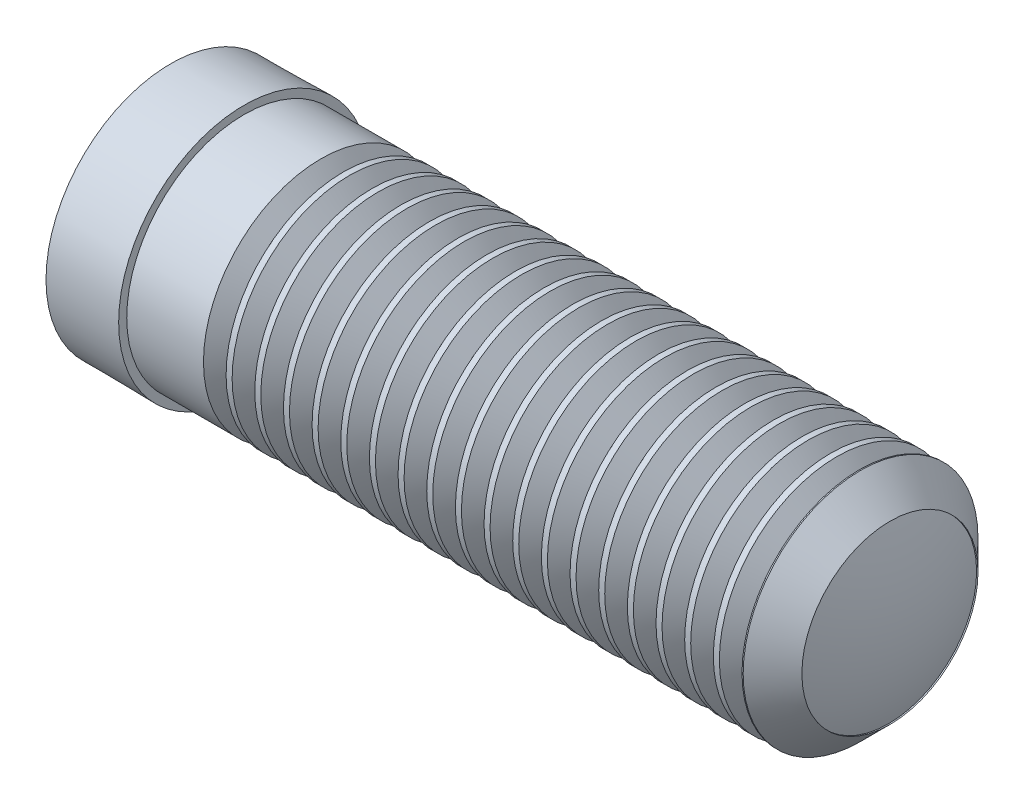
from build123d import *

# Parameters (mm, degrees)
THDSCHPAT_COUNT = 19
THDSCHPAT_PITCH = 1.952710494


with BuildPart() as part:
    # BodySke → Body (revolve)
    with BuildSketch(Plane.XY):
        with BuildLine():
            Line((0, 0), (0, 8.5))
            Line((0, 8.5), (5, 8.55))
            Line((5, 8.55), (5, 8))
            Line((5, 8), (47, 8))
            Line((47, 8), (49, 6))
            Line((49, 6), (48.905973721, 6))
            ThreePointArc((48.905973721, 6), (49.724257132, 3.049462801), (50, 0))
            Line((50, 0), (0, 0))
        make_face()
    revolve(axis=Axis((-8.740321592, 0, 0), (1, 0, 0)))

    # ThdSchSke → ThreadSchematic (revolve, cut)
    with BuildSketch(Plane.XY):
        Polygon((11, 6.8985), (10.19371102, 8.05), (11.80628898, 8.05), align=None)
    threadschematic = revolve(axis=Axis((112.074944318, 0, 0), (1, 0, 0)), mode=Mode.SUBTRACT)

    # ThdSchPat: ThreadSchematic ×19
    with Locations(*[(i * THDSCHPAT_PITCH, 0, 0) for i in range(1, THDSCHPAT_COUNT)]):
        add(threadschematic, mode=Mode.SUBTRACT)


solid = part.part
